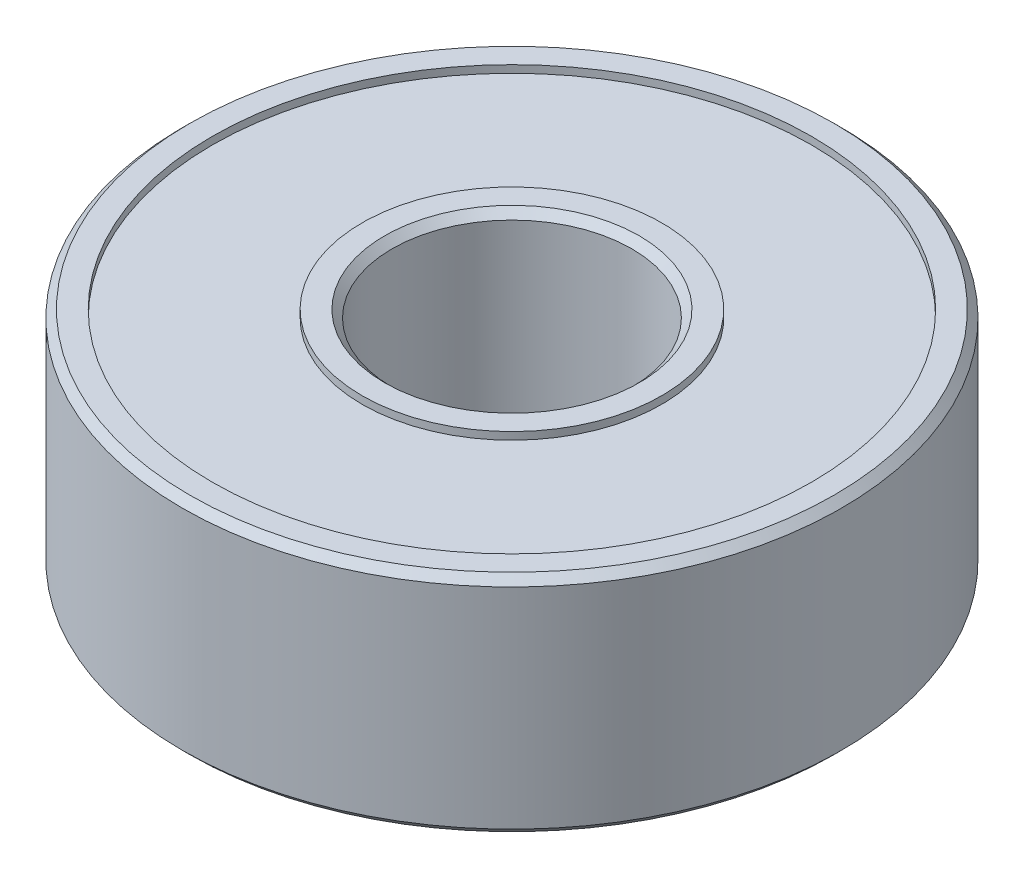
from build123d import *

# Parameters (mm, degrees)
EXTRUDE1_DEPTH        = 3.75
EXTRUDE1_DEPTH_BACK   = 3.75
SKETCH1_R             = 5
SKETCH1_R_2           = 4
EXTRUDE1_2_DEPTH      = 3.75
EXTRUDE1_2_DEPTH_BACK = 3.75
SKETCH1_R_3           = 11
SKETCH1_R_4           = 10
EXTRUDE2_DEPTH        = 3.5
EXTRUDE2_DEPTH_BACK   = 3.5
SKETCH1_4_R           = 10
SKETCH1_4_R_2         = 5
CHAMFER1_SIZE         = 0.25
CHAMFER2_SIZE         = 0.25
CHAMFER3_SIZE         = 0.25


with BuildPart() as part:
    # Sketch1 → Extrude1 (new, two sides: drawn at the far end of the back side and taken through both)
    with BuildSketch(Plane(origin=(0, 0, 0), x_dir=(1, 0, 0), z_dir=(0, 1, 0)).offset(-EXTRUDE1_DEPTH_BACK)):
        Circle(SKETCH1_R)
        Circle(SKETCH1_R_2, mode=Mode.SUBTRACT)
    extrude(amount=EXTRUDE1_DEPTH + EXTRUDE1_DEPTH_BACK)

    # Chamfer3
    chamfer3_edges = [part.edges().sort_by_distance(p)[0] for p in [
        (-4, 3.75, 0),
        (-4, -3.75, 0),
    ]]
    chamfer(chamfer3_edges, length=CHAMFER3_SIZE)


with BuildPart() as body_2:
    # Sketch1 → Extrude1 2 (new, two sides: drawn at the far end of the back side and taken through both)
    with BuildSketch(Plane(origin=(0, 0, 0), x_dir=(1, 0, 0), z_dir=(0, 1, 0)).offset(-EXTRUDE1_2_DEPTH_BACK)):
        Circle(SKETCH1_R_3)
        Circle(SKETCH1_R_4, mode=Mode.SUBTRACT)
    extrude(amount=EXTRUDE1_2_DEPTH + EXTRUDE1_2_DEPTH_BACK)

    # Chamfer1
    chamfer1_edges = [body_2.edges().sort_by_distance(p)[0] for p in [
        (-11, 3.75, 0),
    ]]
    chamfer(chamfer1_edges, length=CHAMFER1_SIZE)

    # Chamfer2
    chamfer2_edges = [body_2.edges().sort_by_distance(p)[0] for p in [
        (-11, -3.75, 0),
    ]]
    chamfer(chamfer2_edges, length=CHAMFER2_SIZE)


with BuildPart() as body_3:
    # Sketch1_4 → Extrude2 (new, two sides: drawn at the far end of the back side and taken through both)
    with BuildSketch(Plane(origin=(0, 0, 0), x_dir=(1, 0, 0), z_dir=(0, 1, 0)).offset(-EXTRUDE2_DEPTH_BACK)):
        Circle(SKETCH1_4_R)
        Circle(SKETCH1_4_R_2, mode=Mode.SUBTRACT)
    extrude(amount=EXTRUDE2_DEPTH + EXTRUDE2_DEPTH_BACK)


solid = Compound([part.part, body_2.part, body_3.part])
